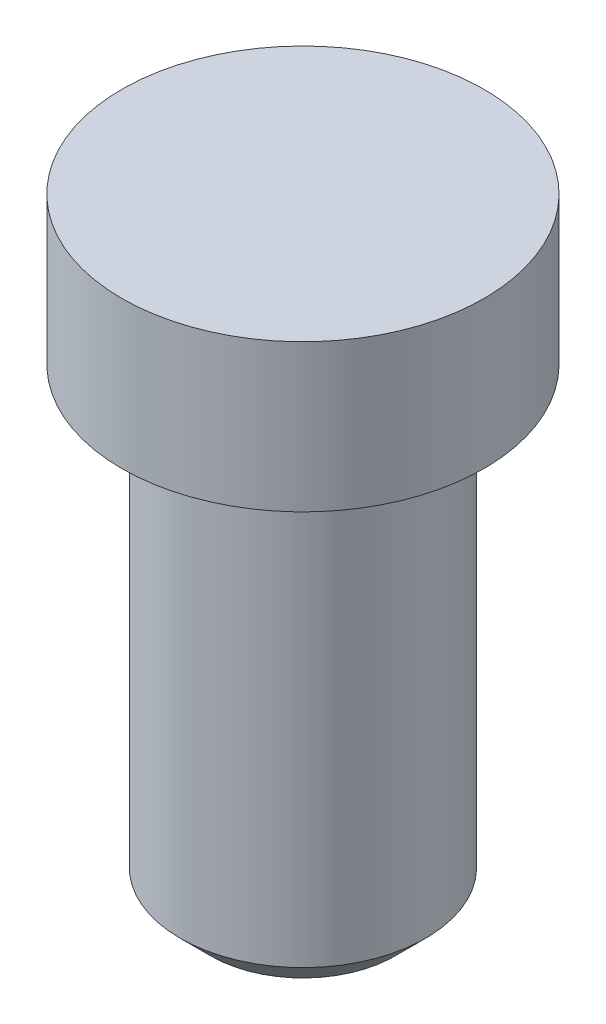
from build123d import *

# Parameters (mm, degrees)
CHAFL_N1_SIZE = 0.5


with BuildPart() as part:
    # Croquis1 → Revolución1 (revolve)
    with BuildSketch(Plane.XY):
        Polygon((0, 0), (2.95, 0), (2.95, -2.4), (2, -2.4), (2, -10), (0, -10), align=None)
    revolve(axis=Axis((0, 0, 0), (0, -1, 0)))

    # Chaflán1
    chafl_n1_edges = [part.edges().sort_by_distance(p)[0] for p in [
        (-2, -10, 0),
    ]]
    chamfer(chafl_n1_edges, length=CHAFL_N1_SIZE)


solid = part.part
